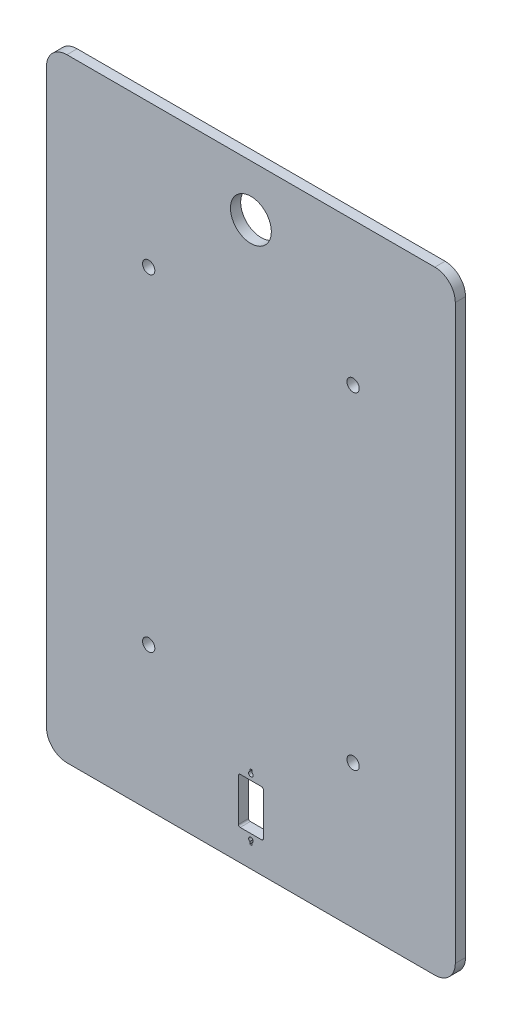
from build123d import *

# Parameters (mm, degrees)
SKETCH1_R           = 10
SKETCH1_R_2         = 3
BOSS_EXTRUDE1_DEPTH = 5


with BuildPart() as part:
    # Sketch1 → Boss-Extrude1 (new body)
    with BuildSketch(Plane.XY):
        with BuildLine():
            Line((-90, 150), (90, 150))
            ThreePointArc((90, 150), (97.071067812, 147.071067812), (100, 140))
            Line((100, 140), (100, -140))
            ThreePointArc((100, -140), (97.071067812, -147.071067812), (90, -150))
            Line((90, -150), (-90, -150))
            ThreePointArc((-90, -150), (-97.071067812, -147.071067812), (-100, -140))
            Line((-100, -140), (-100, 140))
            ThreePointArc((-100, 140), (-97.071067812, 147.071067812), (-90, 150))
        make_face()
        with Locations((0, 125)):
            Circle(SKETCH1_R, mode=Mode.SUBTRACT)
        with Locations((50, 80)):
            Circle(SKETCH1_R_2, mode=Mode.SUBTRACT)
        with Locations((-50, 80)):
            Circle(SKETCH1_R_2, mode=Mode.SUBTRACT)
        with Locations((-50, -80)):
            Circle(SKETCH1_R_2, mode=Mode.SUBTRACT)
        with Locations((50, -80)):
            Circle(SKETCH1_R_2, mode=Mode.SUBTRACT)
        with BuildLine():
            Line((-0.55, -138.602627944), (-0.55, -139.8))
            Line((-0.55, -139.8), (0.55, -139.8))
            Line((0.55, -139.8), (0.55, -138.602627944))
            ThreePointArc((0.55, -138.602627944), (0, -136.55), (-0.55, -138.602627944))
        make_face(mode=Mode.SUBTRACT)
        with BuildLine():
            Line((-0.55, -107.7), (-0.55, -108.897372056))
            ThreePointArc((-0.55, -108.897372056), (0, -110.95), (0.55, -108.897372056))
            Line((0.55, -108.897372056), (0.55, -107.7))
            Line((0.55, -107.7), (-0.55, -107.7))
        make_face(mode=Mode.SUBTRACT)
        with BuildLine():
            Line((-6.1, -113.35), (-6.1, -134.15))
            ThreePointArc((-6.1, -134.15), (-5.851040764, -134.751040764), (-5.25, -135))
            Line((-5.25, -135), (5.25, -135))
            ThreePointArc((5.25, -135), (5.851040764, -134.751040764), (6.1, -134.15))
            Line((6.1, -134.15), (6.1, -113.35))
            ThreePointArc((6.1, -113.35), (5.851040764, -112.748959236), (5.25, -112.5))
            Line((5.25, -112.5), (-5.25, -112.5))
            ThreePointArc((-5.25, -112.5), (-5.851040764, -112.748959236), (-6.1, -113.35))
        make_face(mode=Mode.SUBTRACT)
    extrude(amount=BOSS_EXTRUDE1_DEPTH)


solid = part.part
